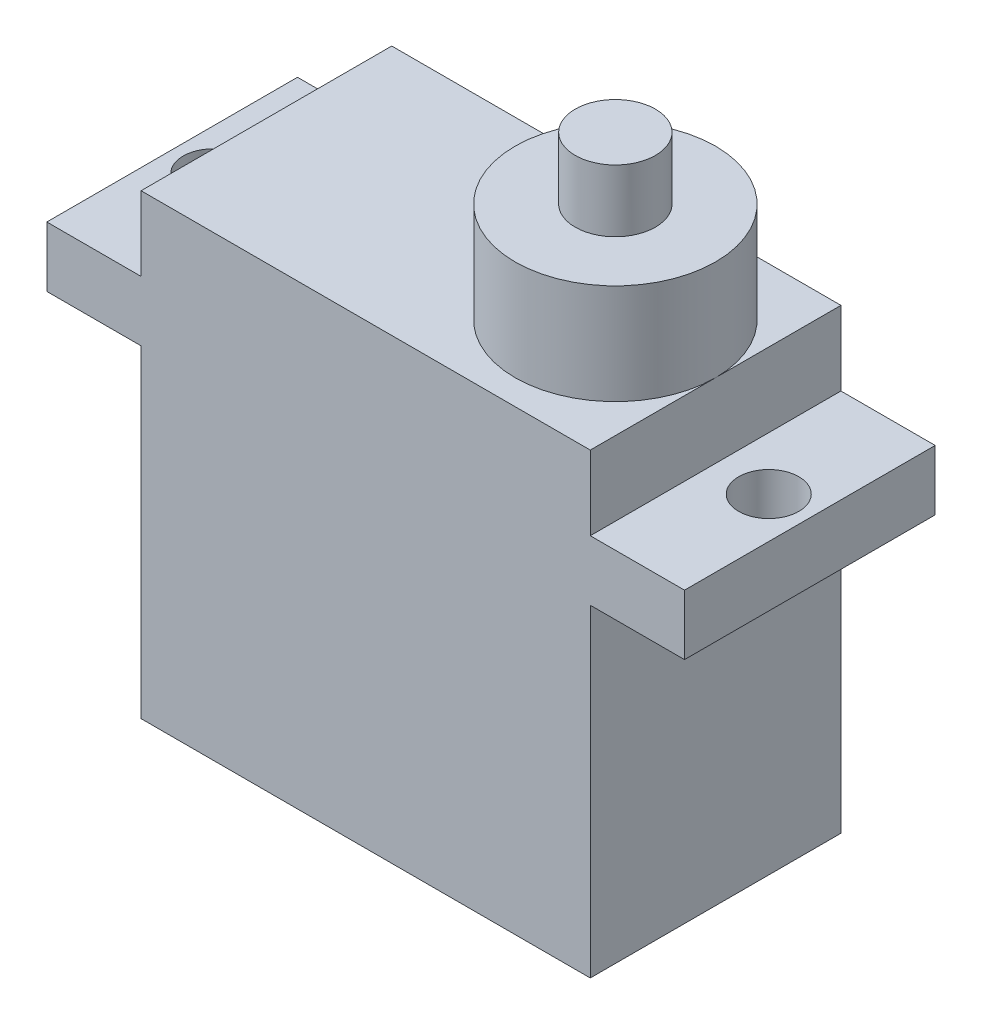
from build123d import *

# Parameters (mm, degrees)
SKETCH_1_W      = 22.4
SKETCH_1_H      = 12.5
EXTRUDE_1_DEPTH = 16.1
SKETCH_2_W      = 31.8
SKETCH_2_H      = 12.5
SKETCH_2_R      = 1.5
EXTRUDE_2_DEPTH = 3
SKETCH_3_W      = 22.4
SKETCH_3_H      = 12.5
EXTRUDE_3_DEPTH = 22.8
SKETCH_4_R      = 5
EXTRUDE_4_DEPTH = 5
SKETCH_5_R      = 2
EXTRUDE_5_DEPTH = 30.9


with BuildPart() as part:
    # 草图1 → 凸台-拉伸1 (new body)
    with BuildSketch(Plane(origin=(0, 0, 0), x_dir=(1, 0, 0), z_dir=(0, 1, 0))):
        Rectangle(SKETCH_1_W, SKETCH_1_H)
    extrude(amount=EXTRUDE_1_DEPTH)

    # 草图2 → 凸台-拉伸2 (add)
    with BuildSketch(Plane(origin=(0, 16.1, 0), x_dir=(1, 0, 0), z_dir=(0, 1, 0))):
        Rectangle(SKETCH_2_W, SKETCH_2_H)
        with Locations((13.85, 0)):
            Circle(SKETCH_2_R, mode=Mode.SUBTRACT)
        with Locations((-13.85, 0)):
            Circle(SKETCH_2_R, mode=Mode.SUBTRACT)
    extrude(amount=EXTRUDE_2_DEPTH)

    # 草图3 → 凸台-拉伸3 (add)
    with BuildSketch(Plane.XZ):
        Rectangle(SKETCH_3_W, SKETCH_3_H)
    extrude(amount=-EXTRUDE_3_DEPTH)

    # 草图4 → 凸台-拉伸4 (add)
    with BuildSketch(Plane(origin=(0, 22.8, 0), x_dir=(1, 0, 0), z_dir=(0, 1, 0))):
        with Locations((6.2, 0)):
            Circle(SKETCH_4_R)
    extrude(amount=EXTRUDE_4_DEPTH)

    # 草图5 → 凸台-拉伸5 (add)
    with BuildSketch(Plane.XZ):
        with Locations((6.2, 0)):
            Circle(SKETCH_5_R)
    extrude(amount=-EXTRUDE_5_DEPTH)


solid = part.part
